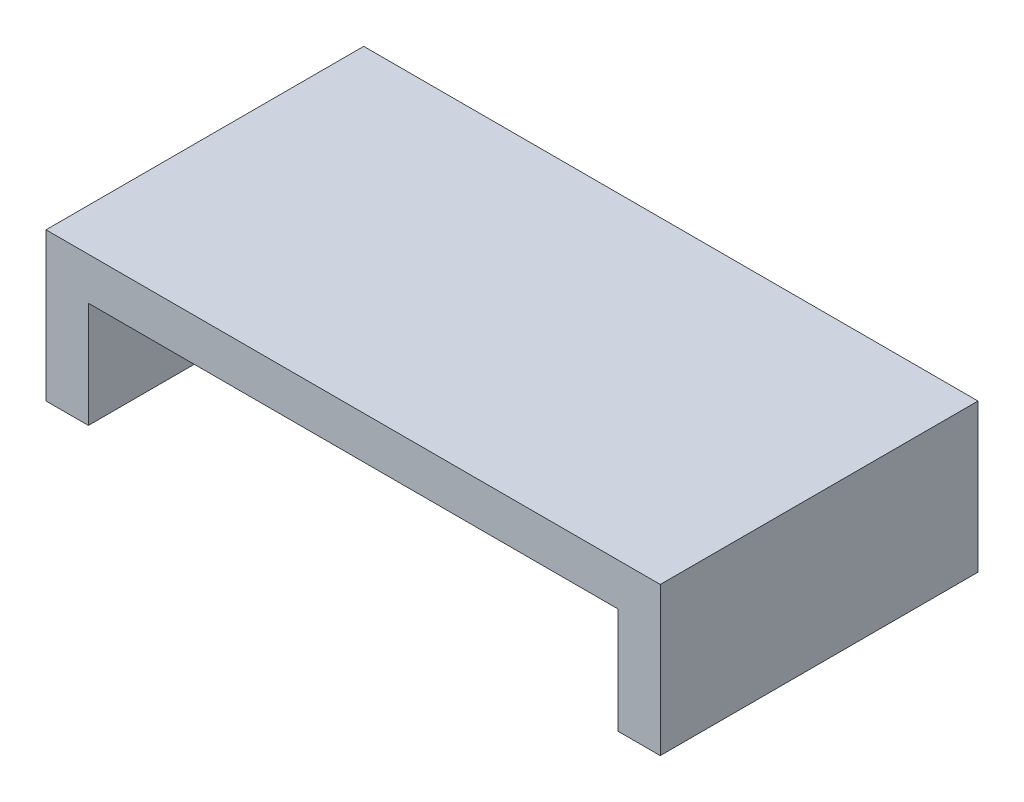
from build123d import *

# Parameters (mm, degrees)
BOSS_EXTRUDE1_DEPTH = 150


with BuildPart() as part:
    # Sketch1 → Boss-Extrude1 (new body)
    with BuildSketch(Plane.XY):
        Polygon((0, 0), (0, 70), (290, 70), (290, 0), (270, 0), (270, 50), (20, 50), (20, 0), align=None)
    extrude(amount=BOSS_EXTRUDE1_DEPTH)


solid = part.part
